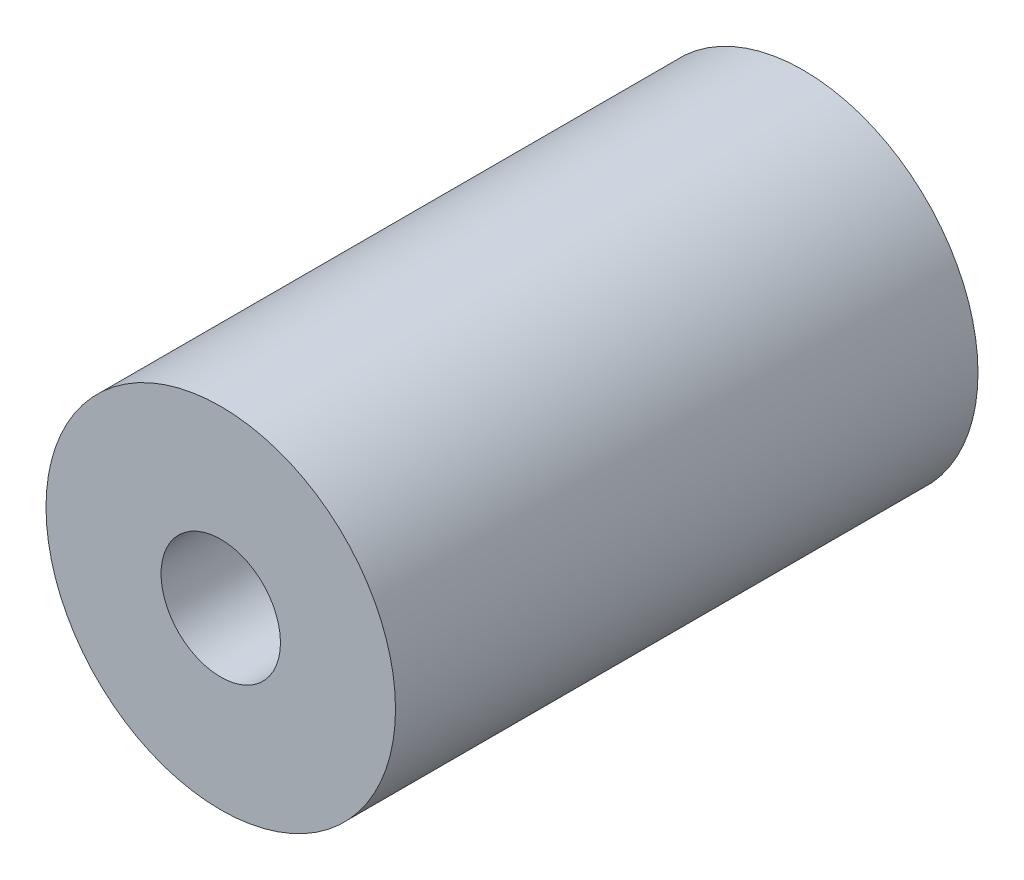
from build123d import *

# Parameters (mm, degrees)
SKETCH1_R           = 3
BOSS_EXTRUDE1_DEPTH = 10
M2_5_TAPPED_HOLE1_D = 2.05


with BuildPart() as part:
    # Sketch1 → Boss-Extrude1 (new body)
    with BuildSketch(Plane.XY):
        Circle(SKETCH1_R)
    extrude(amount=BOSS_EXTRUDE1_DEPTH)

    # M2.5 Tapped Hole1 (through all)
    with Locations(Plane.XY.offset(10)):
        with Locations((0, 0)):
            Hole(M2_5_TAPPED_HOLE1_D / 2)


solid = part.part
